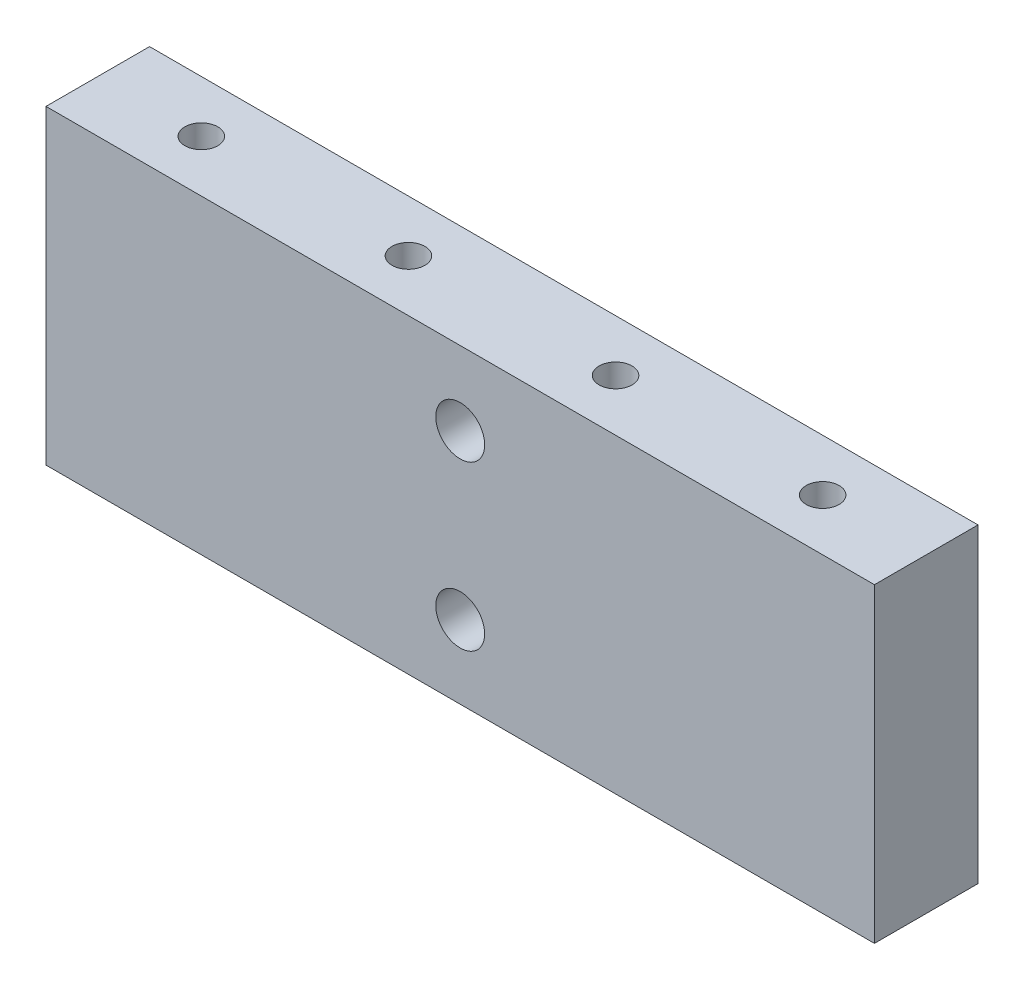
from build123d import *

# Parameters (mm, degrees)
SKETCH1_W              = 101.6
SKETCH1_H              = 38.1
BOSS_EXTRUDE1_DEPTH    = 12.7
F_4_0MM_DOWEL_HOLE1_D  = 4
SKETCH7_R              = 2.9972
CUT_EXTRUDE1_DEPTH     = 5.08
F_10_32_TAPPED_HOLE1_D = 4.0386


with BuildPart() as part:
    # Sketch1 → Boss-Extrude1 (new body)
    with BuildSketch(Plane.XY):
        Rectangle(SKETCH1_W, SKETCH1_H)
    extrude(amount=BOSS_EXTRUDE1_DEPTH)

    # Ø4.0mm Dowel Hole1 (through all)
    with Locations(Plane.XY.offset(12.7)):
        with Locations((0, 9.99998), (0, -9.99998)):
            Hole(F_4_0MM_DOWEL_HOLE1_D / 2)

    # Sketch7 → Cut-Extrude1 (cut)
    with BuildSketch(Plane.XY.offset(12.7)):
        with Locations((0, -10.079486129)):
            Circle(SKETCH7_R)
        with Locations((0, 9.99998)):
            Circle(SKETCH7_R)
    extrude(amount=-CUT_EXTRUDE1_DEPTH, mode=Mode.SUBTRACT)

    # #10-32 Tapped Hole1 (through all)
    with Locations(Plane(origin=(0, 19.05, 0), x_dir=(1, 0, 0), z_dir=(0, 1, 0))):
        with Locations((38.1, -6.35), (12.7, -6.35), (-12.7, -6.35), (-38.1, -6.35)):
            Hole(F_10_32_TAPPED_HOLE1_D / 2)


solid = part.part
